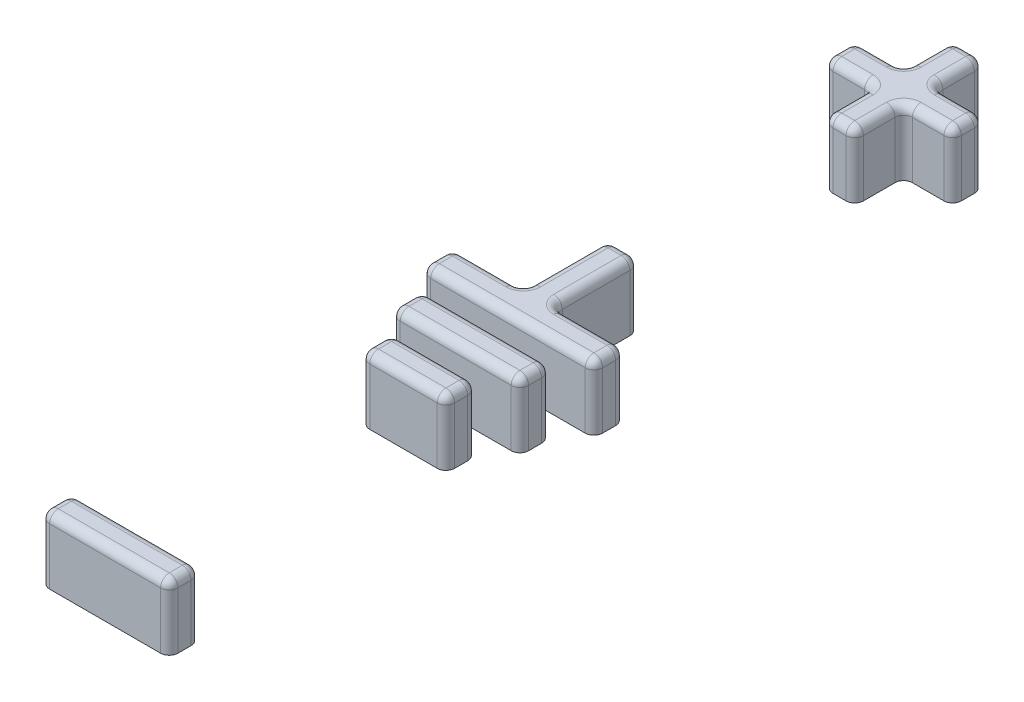
from build123d import *

# Parameters (mm, degrees)
BOSS_EXTRUDE3_DEPTH   = 3
BOSS_EXTRUDE3_2_DEPTH = 3
SKETCH3_W             = 5.9
SKETCH3_H             = 1.4
BOSS_EXTRUDE3_3_DEPTH = 3
BOSS_EXTRUDE3_4_DEPTH = 3
SKETCH3_W_2           = 3.9
BOSS_EXTRUDE3_5_DEPTH = 3
FILLET1_R             = 0.4
FILLET2_R             = 0.4
FILLET3_R             = 0.4
FILLET4_R             = 0.4
FILLET5_R             = 0.4


with BuildPart() as part:
    # Sketch3 → Boss-Extrude3 (new body)
    with BuildSketch(Plane(origin=(0, 0, 0), x_dir=(1, 0, 0), z_dir=(0, 1, 0))):
        Polygon((-0.7, 15.235595234), (0.7, 15.235595234), (0.7, 17.485595234), (2.95, 17.485595234), (2.95, 18.885595234), (0.7, 18.885595234), (0.7, 21.135595234), (-0.7, 21.135595234), (-0.7, 18.885595234), (-2.95, 18.885595234), (-2.95, 17.485595234), (-0.7, 17.485595234), align=None)
    extrude(amount=BOSS_EXTRUDE3_DEPTH)

    # Fillet1
    fillet1_edges = [part.edges().sort_by_distance(p)[0] for p in [
        (-0.7, 3, -20.010595234),
        (-1.825, 3, -18.885595234),
        (0.7, 1.5, -18.885595234),
        (2.95, 1.5, -18.885595234),
        (2.95, 1.5, -17.485595234),
        (-2.95, 3, -18.185595234),
        (0.7, 1.5, -17.485595234),
        (0.7, 1.5, -15.235595234),
        (-0.7, 1.5, -15.235595234),
        (-0.7, 1.5, -17.485595234),
        (-2.95, 1.5, -17.485595234),
        (-2.95, 1.5, -18.885595234),
        (-0.7, 1.5, -18.885595234),
        (-0.7, 1.5, -21.135595234),
        (0.7, 1.5, -21.135595234),
        (-1.825, 3, -17.485595234),
        (-0.7, 3, -16.360595234),
        (0, 3, -15.235595234),
        (0.7, 3, -16.360595234),
        (1.825, 3, -17.485595234),
        (2.95, 3, -18.185595234),
        (1.825, 3, -18.885595234),
        (0.7, 3, -20.010595234),
        (0, 3, -21.135595234),
    ]]
    fillet(fillet1_edges, radius=FILLET1_R)


with BuildPart() as body_2:
    # Sketch3 → Boss-Extrude3 2 (new body)
    with BuildSketch(Plane(origin=(0, 0, 0), x_dir=(1, 0, 0), z_dir=(0, 1, 0))):
        Polygon((0.7, 1.4), (3.95, 1.4), (3.95, 0), (-3.95, 0), (-3.95, 1.4), (-0.7, 1.4), (-0.7, 5.3), (0.7, 5.3), align=None)
    extrude(amount=BOSS_EXTRUDE3_2_DEPTH)

    # Fillet2
    fillet2_edges = [body_2.edges().sort_by_distance(p)[0] for p in [
        (-0.7, 3, -3.35),
        (0.7, 1.5, -1.4),
        (3.95, 1.5, -1.4),
        (3.95, 1.5, 0),
        (-3.95, 1.5, 0),
        (-3.95, 1.5, -1.4),
        (-0.7, 1.5, -1.4),
        (-0.7, 1.5, -5.3),
        (0.7, 1.5, -5.3),
        (-2.325, 3, -1.4),
        (-3.95, 3, -0.7),
        (0, 3, 0),
        (3.95, 3, -0.7),
        (2.325, 3, -1.4),
        (0.7, 3, -3.35),
        (0, 3, -5.3),
    ]]
    fillet(fillet2_edges, radius=FILLET2_R)


with BuildPart() as body_3:
    # Sketch3 → Boss-Extrude3 3 (new body)
    with BuildSketch(Plane(origin=(0, 0, 0), x_dir=(1, 0, 0), z_dir=(0, 1, 0))):
        with Locations((0, -17.814404766)):
            Rectangle(SKETCH3_W, SKETCH3_H)
    extrude(amount=BOSS_EXTRUDE3_3_DEPTH)

    # Fillet5
    fillet5_edges = [body_3.edges().sort_by_distance(p)[0] for p in [
        (-2.95, 3, 17.814404766),
        (0, 3, 18.514404766),
        (2.95, 3, 17.814404766),
        (2.95, 1.5, 18.514404766),
        (-2.95, 1.5, 18.514404766),
        (-2.95, 1.5, 17.114404766),
        (2.95, 1.5, 17.114404766),
        (0, 3, 17.114404766),
    ]]
    fillet(fillet5_edges, radius=FILLET5_R)


with BuildPart() as body_4:
    # Sketch3 → Boss-Extrude3 4 (new body)
    with BuildSketch(Plane(origin=(0, 0, 0), x_dir=(1, 0, 0), z_dir=(0, 1, 0))):
        with Locations((0, -1.7)):
            Rectangle(SKETCH3_W, SKETCH3_H)
    extrude(amount=BOSS_EXTRUDE3_4_DEPTH)

    # Fillet3
    fillet3_edges = [body_4.edges().sort_by_distance(p)[0] for p in [
        (-2.95, 3, 1.7),
        (0, 3, 2.4),
        (2.95, 3, 1.7),
        (2.95, 1.5, 2.4),
        (-2.95, 1.5, 2.4),
        (-2.95, 1.5, 1),
        (2.95, 1.5, 1),
        (0, 3, 1),
    ]]
    fillet(fillet3_edges, radius=FILLET3_R)


with BuildPart() as body_5:
    # Sketch3 → Boss-Extrude3 5 (new body)
    with BuildSketch(Plane(origin=(0, 0, 0), x_dir=(1, 0, 0), z_dir=(0, 1, 0))):
        with Locations((0, -4.1)):
            Rectangle(SKETCH3_W_2, SKETCH3_H)
    extrude(amount=BOSS_EXTRUDE3_5_DEPTH)

    # Fillet4
    fillet4_edges = [body_5.edges().sort_by_distance(p)[0] for p in [
        (-1.95, 3, 4.1),
        (0, 3, 4.8),
        (1.95, 3, 4.1),
        (1.95, 1.5, 4.8),
        (-1.95, 1.5, 4.8),
        (-1.95, 1.5, 3.4),
        (1.95, 1.5, 3.4),
        (0, 3, 3.4),
    ]]
    fillet(fillet4_edges, radius=FILLET4_R)


solid = Compound([part.part, body_2.part, body_3.part, body_4.part, body_5.part])
